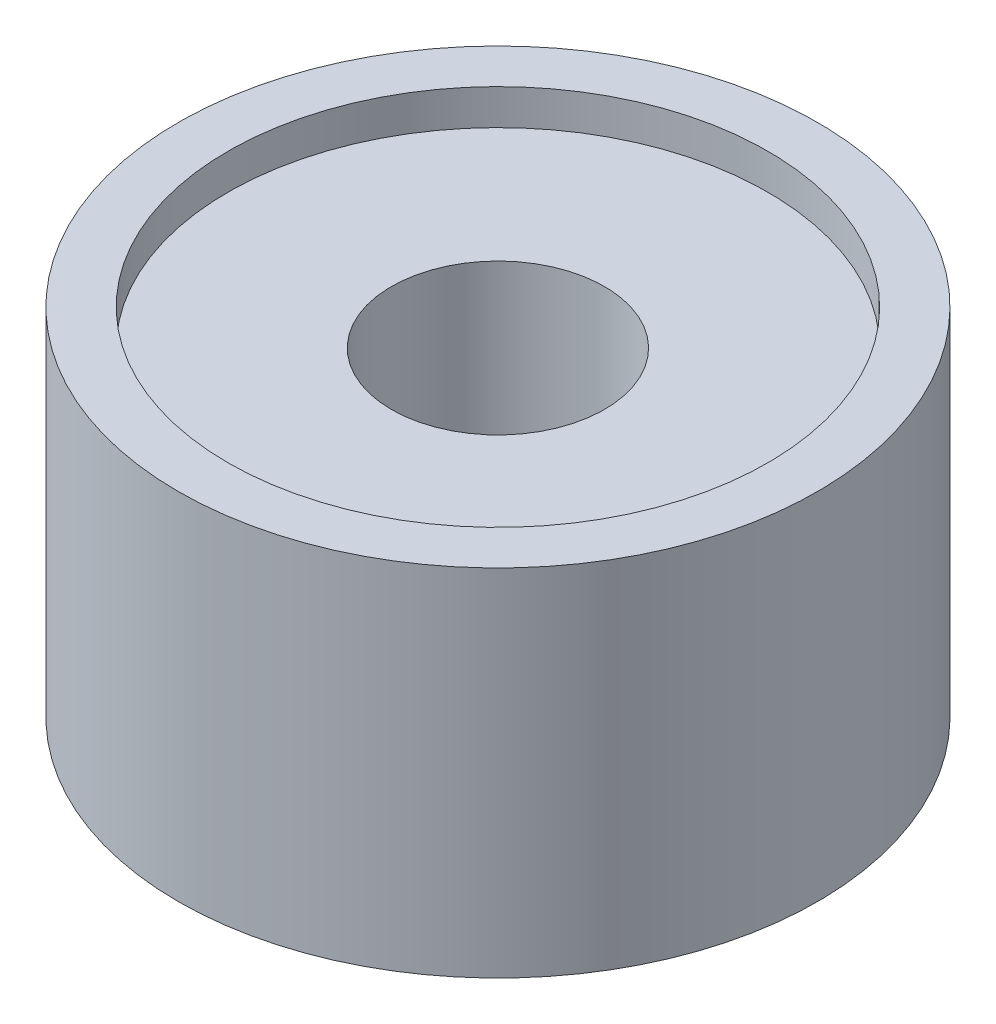
from build123d import *

# Parameters (mm, degrees)
SKETCH1_R           = 4.5
BOSS_EXTRUDE1_DEPTH = 5
SKETCH2_R           = 1.5
CUT_EXTRUDE1_DEPTH  = 6
SKETCH3_R           = 3.8
CUT_EXTRUDE2_DEPTH  = 0.5


with BuildPart() as part:
    # Sketch1 → Boss-Extrude1 (new body)
    with BuildSketch(Plane(origin=(0, 0, 0), x_dir=(1, 0, 0), z_dir=(0, 1, 0))):
        Circle(SKETCH1_R)
    extrude(amount=BOSS_EXTRUDE1_DEPTH)

    # Sketch2 → Cut-Extrude1 (cut, through all)
    with BuildSketch(Plane(origin=(0, 5, 0), x_dir=(1, 0, 0), z_dir=(0, 1, 0))):
        Circle(SKETCH2_R)
    extrude(amount=-CUT_EXTRUDE1_DEPTH, mode=Mode.SUBTRACT)

    # Sketch3 → Cut-Extrude2 (cut)
    with BuildSketch(Plane(origin=(0, 5, 0), x_dir=(1, 0, 0), z_dir=(0, 1, 0))):
        Circle(SKETCH3_R)
    extrude(amount=-CUT_EXTRUDE2_DEPTH, mode=Mode.SUBTRACT)


solid = part.part
